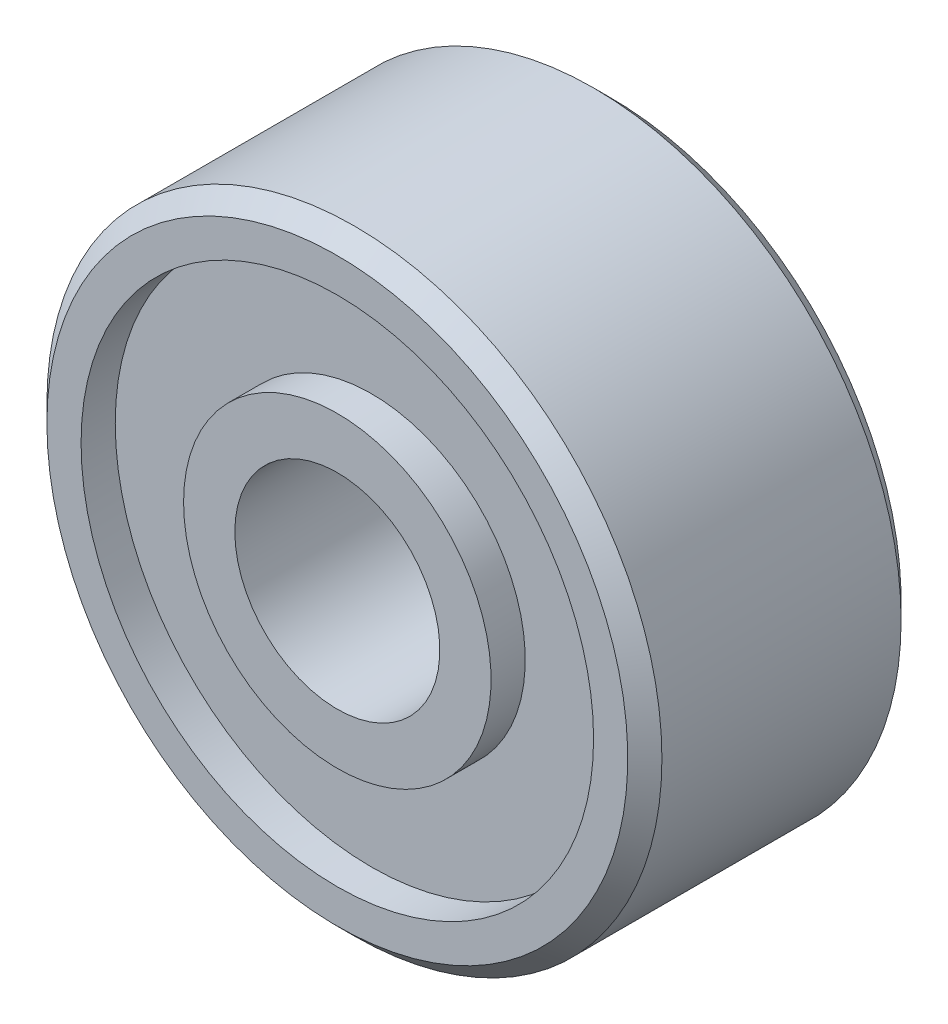
from build123d import *


with BuildPart() as part:
    # Sketch1 → Revolve1 (revolve)
    with BuildSketch(Plane.XZ):
        Polygon((4.5, 1.25), (4.25, 1.5), (3.75, 1.5), (3.75, 1), (2.25, 1), (2.25, 1.5), (1.5, 1.5), (1.5, -2.5), (2.25, -2.5), (2.25, -2), (3.75, -2), (3.75, -2.5), (4.25, -2.5), (4.5, -2.25), align=None)
    revolve(axis=Axis((0, 0, 2.5), (0, 0, -1)))


solid = part.part
